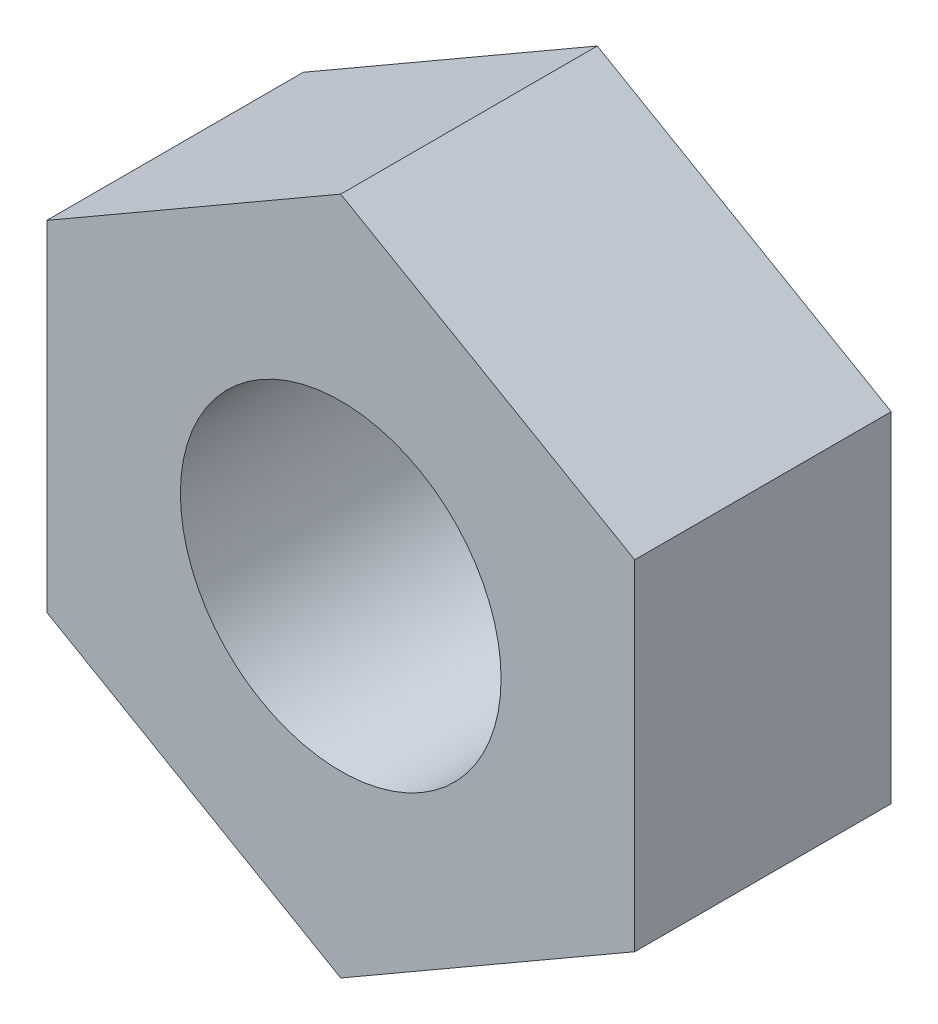
from build123d import *

# Parameters (mm, degrees)
ESQUISSE1_R        = 1.5
BOSS_EXTRU_1_DEPTH = 2.4


with BuildPart() as part:
    # Esquisse1 → Boss.-Extru.1 (new body)
    with BuildSketch(Plane.XY):
        Polygon((0, -3.175426481), (2.75, -1.58771324), (2.75, 1.58771324), (0, 3.175426481), (-2.75, 1.58771324), (-2.75, -1.58771324), align=None)
        Circle(ESQUISSE1_R, mode=Mode.SUBTRACT)
    extrude(amount=BOSS_EXTRU_1_DEPTH)


solid = part.part
